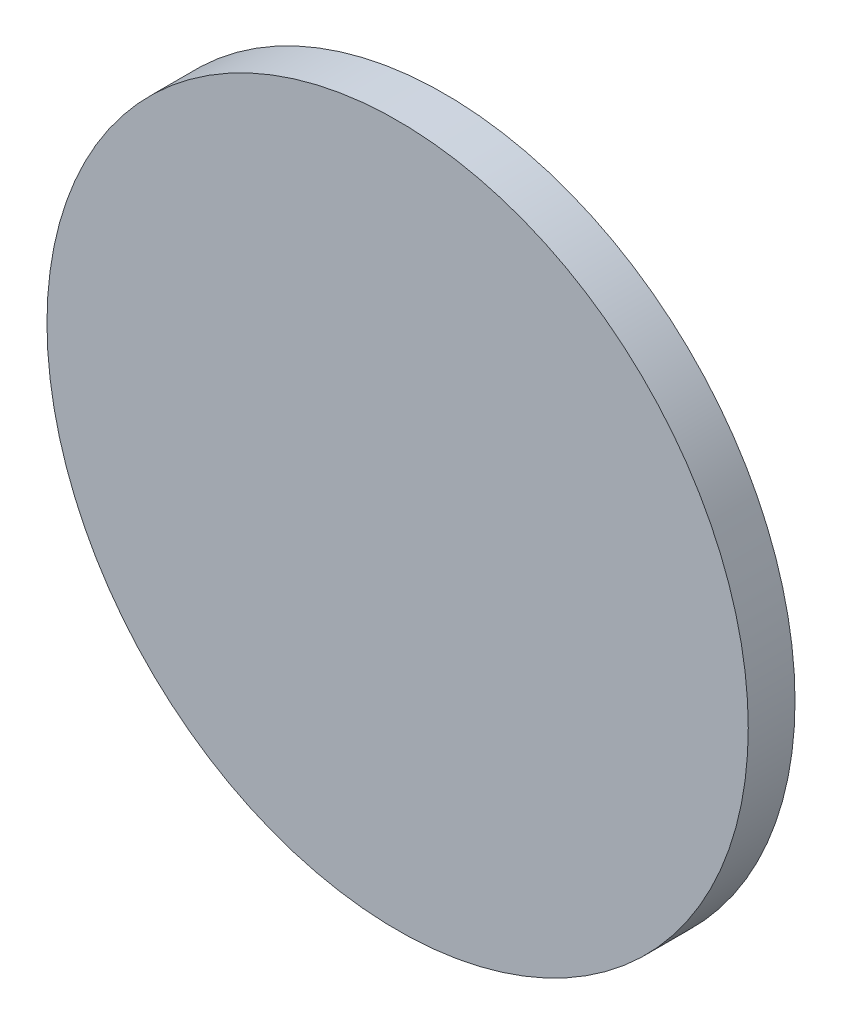
from build123d import *

# Parameters (mm, degrees)
SKETCH2_R           = 22.5
BOSS_EXTRUDE1_DEPTH = 3


with BuildPart() as part:
    # Sketch2 → Boss-Extrude1 (new body)
    with BuildSketch(Plane.XY):
        Circle(SKETCH2_R)
    extrude(amount=BOSS_EXTRUDE1_DEPTH)


solid = part.part
